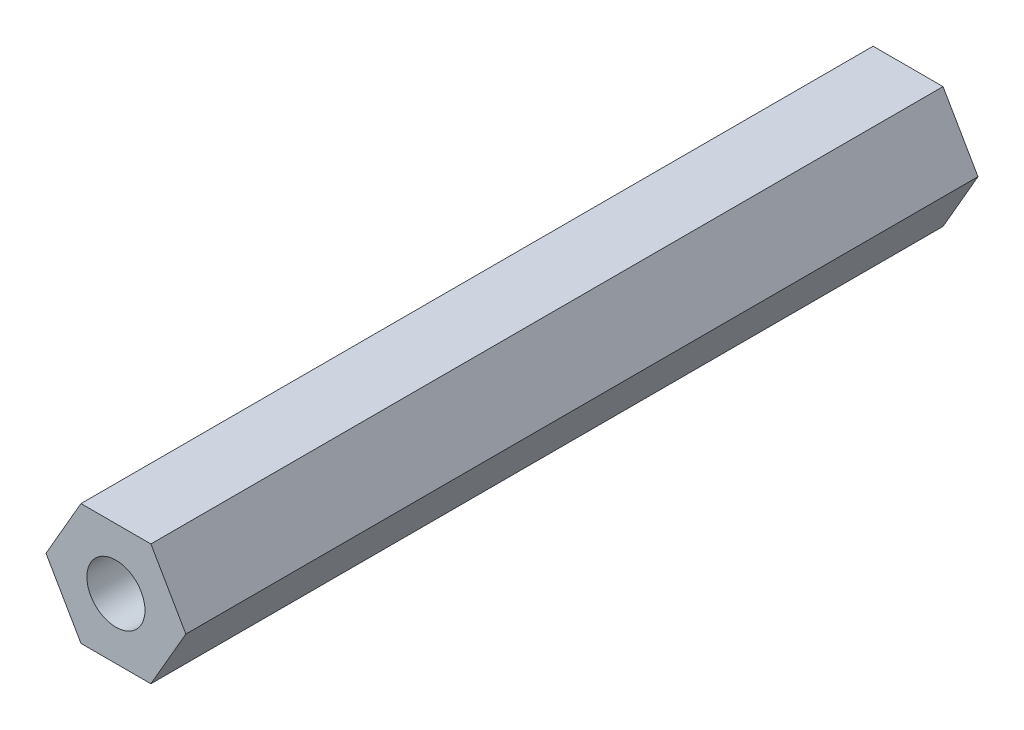
from build123d import *

# Parameters (mm, degrees)
EXTRUDE_340_DEPTH = 22.5


with BuildPart() as part:
    # 草图1 → Extrude 340 (new body, symmetric)
    with BuildSketch(Plane.XY):
        Polygon((1.986084926, 3.44), (-1.986084926, 3.44), (-3.972169852, 0), (-1.986084926, -3.44), (1.986084926, -3.44), (3.972169852, 0), align=None)
    extrude(amount=EXTRUDE_340_DEPTH, both=True)

    # 草图3 → 螺纹孔1 (revolve, cut)
    with BuildSketch(Plane(origin=(0, 0, 22.5), x_dir=(0, -1, 0), z_dir=(1, 0, 0))):
        Polygon((0, 0), (0, 14.191420021), (1.65, 13.2), (1.65, 0), align=None)
    hole_wizard_1 = revolve(axis=Axis((0, 0, 28.85), (0, 0, -1)), mode=Mode.SUBTRACT)

    # 镜向1: 螺纹孔1 across plane
    add(hole_wizard_1.mirror(Plane.XY), mode=Mode.SUBTRACT)


solid = part.part
